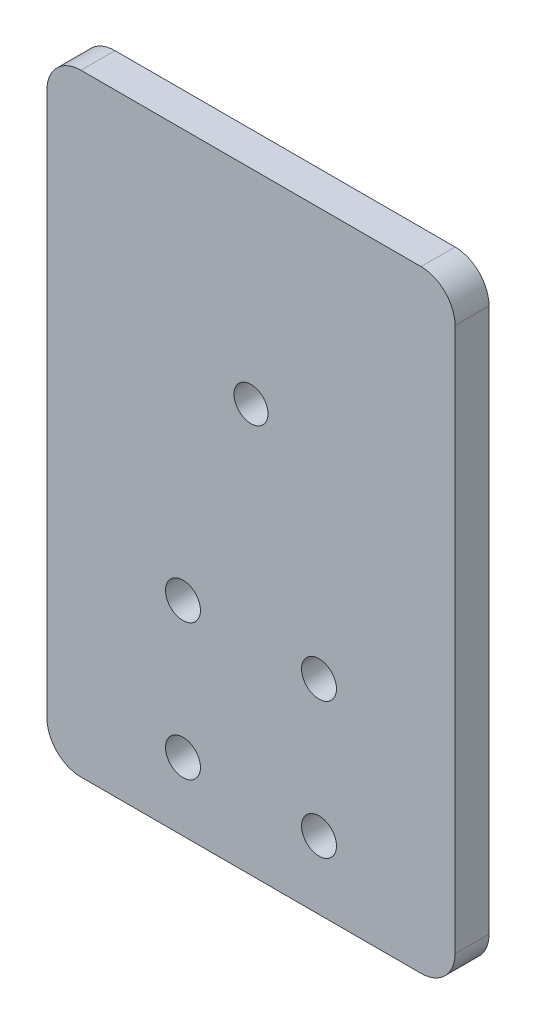
from build123d import *

# Parameters (mm, degrees)
SKETCH1_W      = 76.2
SKETCH1_H      = 114.3
SKETCH1_R      = 3.2639
SKETCH1_R_2    = 3.175
EXTRUDE1_DEPTH = 6.35
FILLET1_R      = 6.35


with BuildPart() as part:
    # Sketch1 → Extrude1 (new body)
    with BuildSketch(Plane.XY):
        with Locations((38.1, 57.15)):
            Rectangle(SKETCH1_W, SKETCH1_H)
        with Locations((25.4, 12.7)):
            Circle(SKETCH1_R, mode=Mode.SUBTRACT)
        with Locations((50.8, 12.7)):
            Circle(SKETCH1_R, mode=Mode.SUBTRACT)
        with Locations((25.4, 38.1)):
            Circle(SKETCH1_R, mode=Mode.SUBTRACT)
        with Locations((50.8, 38.1)):
            Circle(SKETCH1_R, mode=Mode.SUBTRACT)
        with Locations((38.1, 76.2)):
            Circle(SKETCH1_R_2, mode=Mode.SUBTRACT)
    extrude(amount=EXTRUDE1_DEPTH)

    # Fillet1
    fillet1_edges = [part.edges().sort_by_distance(p)[0] for p in [
        (0, 114.3, 3.175),
        (76.2, 114.3, 3.175),
        (76.2, 0, 3.175),
        (0, 0, 3.175),
    ]]
    fillet(fillet1_edges, radius=FILLET1_R)


solid = part.part
